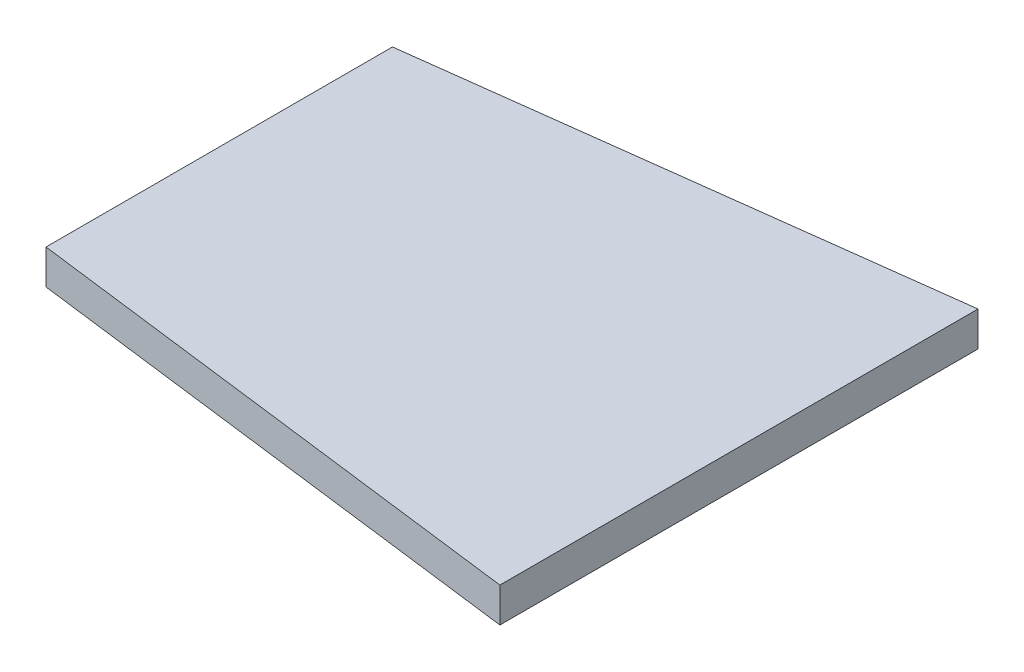
from build123d import *

# Parameters (mm, degrees)
BOSS_EXTRUDE1_DEPTH = 5


with BuildPart() as part:
    # Sketch1 → Boss-Extrude1 (new body)
    with BuildSketch(Plane(origin=(0, 0, 0), x_dir=(1, 0, 0), z_dir=(0, 1, 0))):
        Polygon((0, 25), (75, 34.5), (75, -34.5), (0, -25), align=None)
    extrude(amount=BOSS_EXTRUDE1_DEPTH)


solid = part.part
